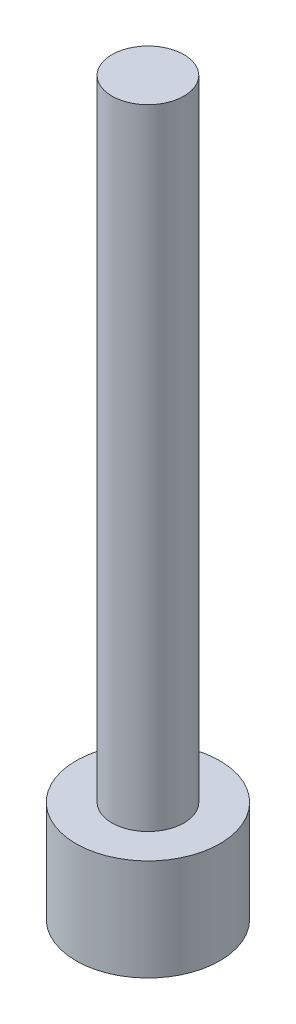
from build123d import *


with BuildPart() as part:
    # Эскиз1 → Повернуть1 (revolve)
    with BuildSketch(Plane(origin=(0, 0, 0), x_dir=(0, 0, -1), z_dir=(1, 0, 0))):
        Polygon((0, 0), (8, 0), (8, 11.281105991), (4, 11.281105991), (4, 81.301763865), (0, 81.301763865), align=None)
    revolve(axis=Axis((0, 101.789289687, 0), (0, -1, 0)))


solid = part.part
